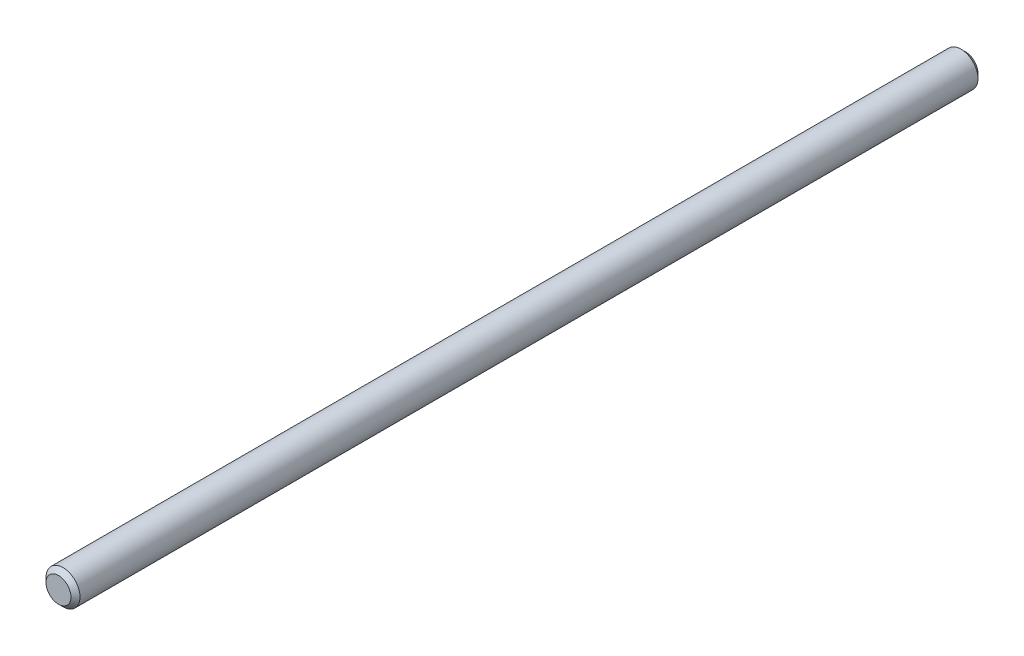
from build123d import *

# Parameters (mm, degrees)
CROQUIS1_R              = 7.5
SALIENTE_EXTRUIR1_DEPTH = 400
CHAFL_N1_SIZE           = 2


with BuildPart() as part:
    # Croquis1 → Saliente-Extruir1 (new body)
    with BuildSketch(Plane.XY):
        Circle(CROQUIS1_R)
    extrude(amount=SALIENTE_EXTRUIR1_DEPTH)

    # Chaflán1
    chafl_n1_edges = [part.edges().sort_by_distance(p)[0] for p in [
        (-7.5, 0, 0),
        (-7.5, 0, 400),
    ]]
    chamfer(chafl_n1_edges, length=CHAFL_N1_SIZE)


solid = part.part
